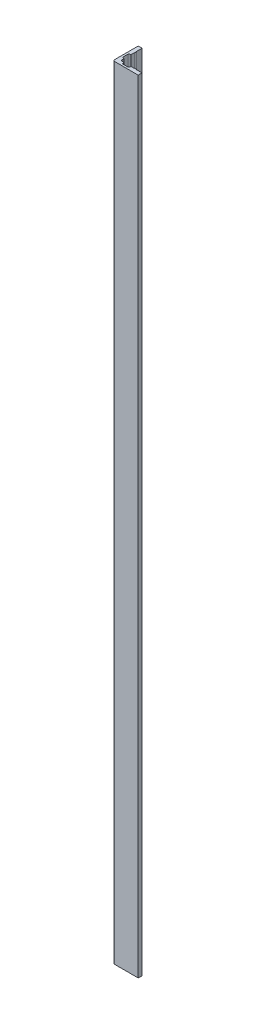
from build123d import *

# Parameters (mm, degrees)
BOSS_EXTRUDE1_DEPTH = 1828.8
SKETCH6_W           = 1
SKETCH6_H           = 4
BOSS_EXTRUDE2_DEPTH = 1828.8
SKETCH7_W           = 4
SKETCH7_H           = 1
BOSS_EXTRUDE3_DEPTH = 1828.8
SKETCH8_W           = 15.75
SKETCH8_H           = 4.5
CUT_EXTRUDE3_DEPTH  = 1829.8
SKETCH9_W           = 4.5
SKETCH9_H           = 15.75
CUT_EXTRUDE4_DEPTH  = 1829.8
FILLET4_R           = 2
FILLET2_R           = 3.66
FILLET3_R           = 3.66


with BuildPart() as part:
    # Sketch2 → Boss-Extrude1 (new body)
    with BuildSketch(Plane(origin=(0, 0, 0), x_dir=(1, 0, 0), z_dir=(0, 1, 0))):
        Polygon((0, 0), (50, 0), (50, -9), (-9, -9), (-9, 50), (0, 50), align=None)
    extrude(amount=BOSS_EXTRUDE1_DEPTH)

    # Sketch6 → Boss-Extrude2 (add, through all)
    with BuildSketch(Plane(origin=(0, 1828.8, 0), x_dir=(1, 0, 0), z_dir=(0, 1, 0))):
        with Locations((0.5, 33.75)):
            Rectangle(SKETCH6_W, SKETCH6_H)
    extrude(amount=-BOSS_EXTRUDE2_DEPTH)

    # Sketch7 → Boss-Extrude3 (add, through all)
    with BuildSketch(Plane(origin=(0, 1828.8, 0), x_dir=(1, 0, 0), z_dir=(0, 1, 0))):
        with Locations((33.75, 0.5)):
            Rectangle(SKETCH7_W, SKETCH7_H)
    extrude(amount=-BOSS_EXTRUDE3_DEPTH)

    # Sketch8 → Cut-Extrude3 (cut, through all)
    with BuildSketch(Plane(origin=(0, 1828.8, 0), x_dir=(1, 0, 0), z_dir=(0, 1, 0))):
        with Locations((15.875, -2.25)):
            Rectangle(SKETCH8_W, SKETCH8_H)
    extrude(amount=-CUT_EXTRUDE3_DEPTH, mode=Mode.SUBTRACT)

    # Sketch9 → Cut-Extrude4 (cut, through all)
    with BuildSketch(Plane(origin=(0, 1828.8, 0), x_dir=(1, 0, 0), z_dir=(0, 1, 0))):
        with Locations((-2.25, 15.875)):
            Rectangle(SKETCH9_W, SKETCH9_H)
    extrude(amount=-CUT_EXTRUDE4_DEPTH, mode=Mode.SUBTRACT)

    # Fillet4
    fillet4_edges = [part.edges().sort_by_distance(p)[0] for p in [
        (8, 914.4, 4.5),
        (23.75, 914.4, 4.5),
        (-4.5, 914.4, -8),
        (-4.5, 914.4, -23.75),
    ]]
    fillet(fillet4_edges, radius=FILLET4_R)

    # Fillet2
    fillet2_edges = [part.edges().sort_by_distance(p)[0] for p in [
        (0, 914.4, 0),
    ]]
    fillet(fillet2_edges, radius=FILLET2_R)

    # Fillet3
    fillet3_edges = [part.edges().sort_by_distance(p)[0] for p in [
        (-9, 914.4, 9),
    ]]
    fillet(fillet3_edges, radius=FILLET3_R)


solid = part.part
